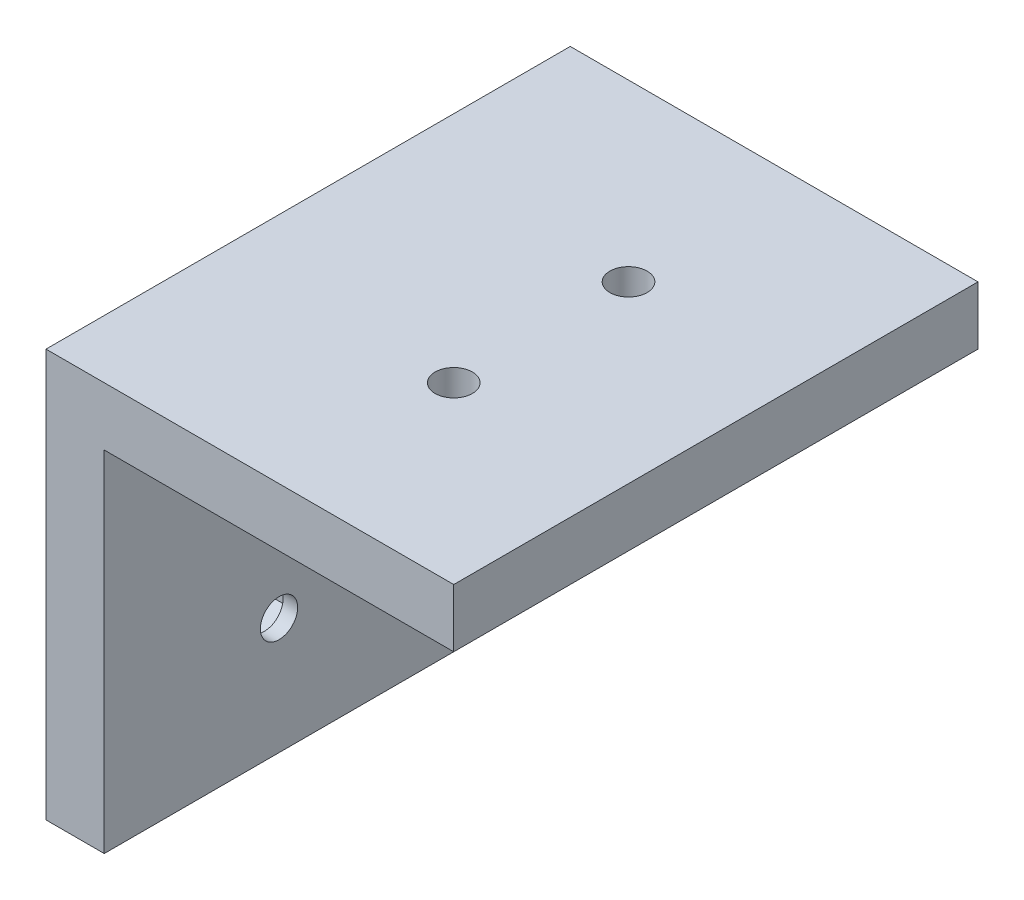
from build123d import *

# Parameters (mm, degrees)
BOSS_EXTRUDE1_DEPTH = 45
CUT_EXTRUDE1_REACH  = 7
SKETCH2_R           = 1.6
CUT_EXTRUDE2_REACH  = 7
SKETCH3_R           = 1.6
CUT_EXTRUDE3_START  = -1.25
CUT_EXTRUDE3_DEPTH  = 2.5


with BuildPart() as part:
    # Sketch1 → Boss-Extrude1 (new body)
    with BuildSketch(Plane.XY):
        Polygon((0, 0), (0, -30), (-5, -30), (-5, 5), (30, 5), (30, 0), align=None)
    extrude(amount=BOSS_EXTRUDE1_DEPTH)

    # Sketch2 → Cut-Extrude1 (cut, up to next)
    with BuildSketch(Plane(origin=(0, 0, 0), x_dir=(0, 0, -1), z_dir=(1, 0, 0)), mode=Mode.PRIVATE) as cut_extrude1_sk1:
        with Locations((-30, -20)):
            Circle(SKETCH2_R)
    cut_extrude1_tool1 = extrude(cut_extrude1_sk1.sketch, amount=-CUT_EXTRUDE1_REACH, mode=Mode.PRIVATE) & part.part
    add(cut_extrude1_tool1.solids().sort_by_distance((0, -20, 30))[0], mode=Mode.SUBTRACT)
    # Sketch2 → Cut-Extrude1 (cut, up to next)
    with BuildSketch(Plane(origin=(0, 0, 0), x_dir=(0, 0, -1), z_dir=(1, 0, 0)), mode=Mode.PRIVATE) as cut_extrude1_sk2:
        with Locations((-15, -20)):
            Circle(SKETCH2_R)
    cut_extrude1_tool2 = extrude(cut_extrude1_sk2.sketch, amount=-CUT_EXTRUDE1_REACH, mode=Mode.PRIVATE) & part.part
    add(cut_extrude1_tool2.solids().sort_by_distance((0, -20, 15))[0], mode=Mode.SUBTRACT)

    # Sketch3 → Cut-Extrude2 (cut, up to next)
    with BuildSketch(Plane.XZ, mode=Mode.PRIVATE) as cut_extrude2_sk1:
        with Locations((15, 30)):
            Circle(SKETCH3_R)
    cut_extrude2_tool1 = extrude(cut_extrude2_sk1.sketch, amount=-CUT_EXTRUDE2_REACH, mode=Mode.PRIVATE) & part.part
    add(cut_extrude2_tool1.solids().sort_by_distance((15, 0, 30))[0], mode=Mode.SUBTRACT)
    # Sketch3 → Cut-Extrude2 (cut, up to next)
    with BuildSketch(Plane.XZ, mode=Mode.PRIVATE) as cut_extrude2_sk2:
        with Locations((15, 15)):
            Circle(SKETCH3_R)
    cut_extrude2_tool2 = extrude(cut_extrude2_sk2.sketch, amount=-CUT_EXTRUDE2_REACH, mode=Mode.PRIVATE) & part.part
    add(cut_extrude2_tool2.solids().sort_by_distance((15, 0, 15))[0], mode=Mode.SUBTRACT)

    # Sketch4 → Cut-Extrude3 (cut)
    with BuildSketch(Plane(origin=(0, 0, 0), x_dir=(0, 0, -1), z_dir=(1, 0, 0)).offset(CUT_EXTRUDE3_START)):
        Polygon((-30, -23.435234102), (-27.025, -21.717617051), (-27.025, -18.282382949), (-30, -16.564765898), (-32.975, -18.282382949), (-32.975, -21.717617051), align=None)
        Polygon((-15, -23.435234102), (-12.025, -21.717617051), (-12.025, -18.282382949), (-15, -16.564765898), (-17.975, -18.282382949), (-17.975, -21.717617051), align=None)
    extrude(amount=-CUT_EXTRUDE3_DEPTH, mode=Mode.SUBTRACT)


solid = part.part
